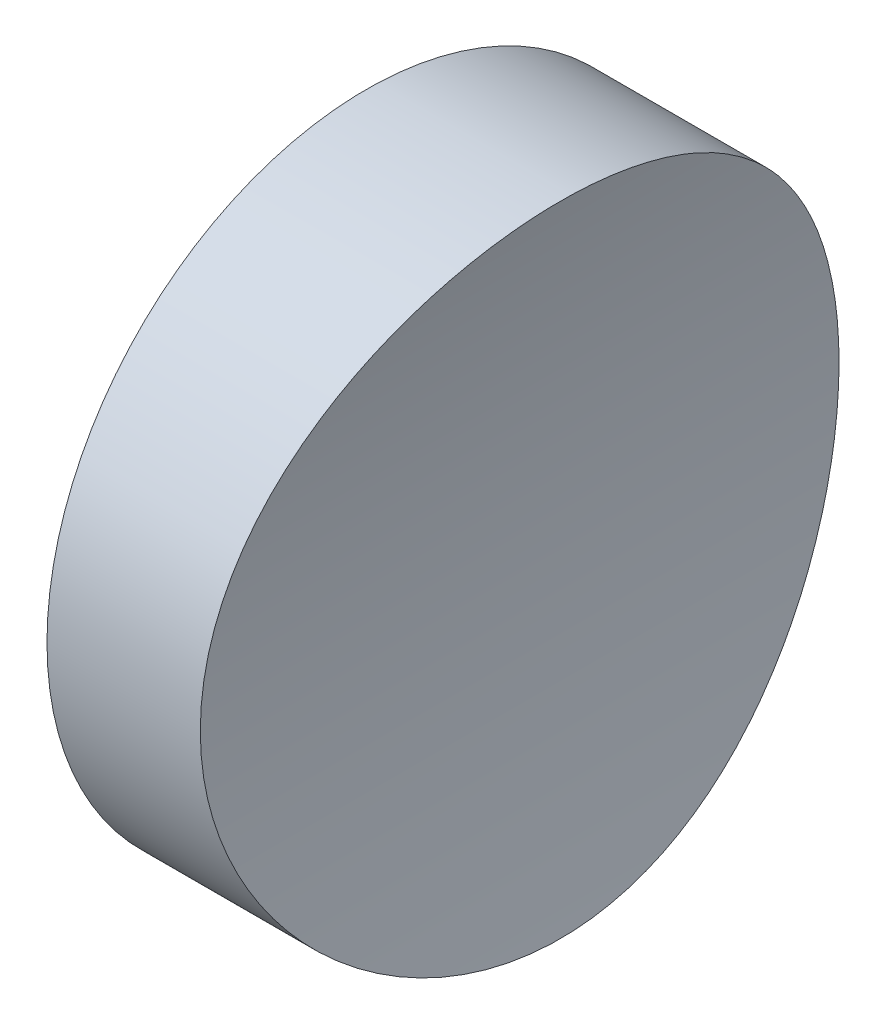
from build123d import *

# Parameters (mm, degrees)
SKETCH_1_R               = 6.25
EXTRUDE_1_DEPTH          = 10
SKETCH_2_R               = 25
CUT_EXTRUDE_1_DEPTH      = 7.25
CUT_EXTRUDE_1_DEPTH_BACK = 7.25


with BuildPart() as part:
    # 草图1 → 凸台-拉伸1 (new body)
    with BuildSketch(Plane(origin=(0, 0, 0), x_dir=(0, 0, -1), z_dir=(1, 0, 0))):
        Circle(SKETCH_1_R)
    extrude(amount=EXTRUDE_1_DEPTH)

    # 草图2 → 切除-拉伸1 (cut, two sides)
    with BuildSketch(Plane.XY) as cut_extrude_1_sk:
        with Locations((28, 0)):
            Circle(SKETCH_2_R)
    extrude(amount=CUT_EXTRUDE_1_DEPTH, mode=Mode.SUBTRACT)
    extrude(cut_extrude_1_sk.sketch, amount=-CUT_EXTRUDE_1_DEPTH_BACK, mode=Mode.SUBTRACT)


solid = part.part
